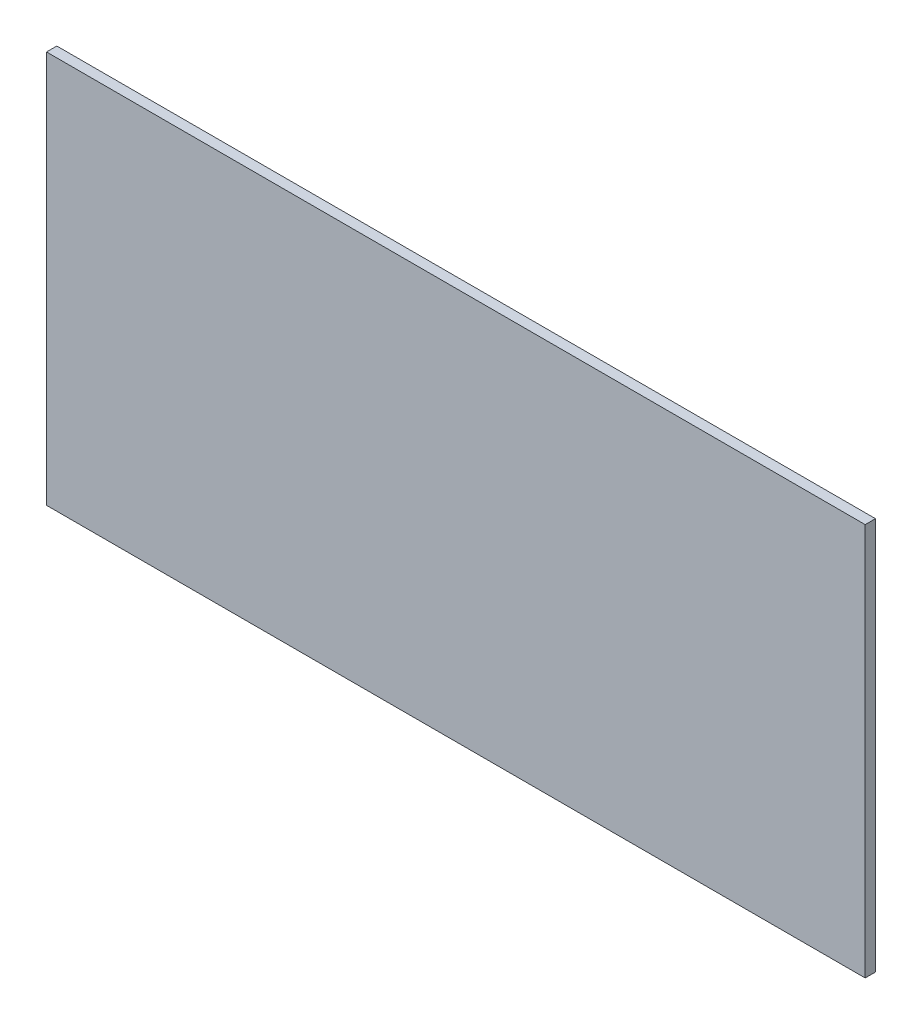
from build123d import *

# Parameters (mm, degrees)
SKETCH1_W           = 946.658829024
SKETCH1_H           = 454.025
BOSS_EXTRUDE1_DEPTH = 11.90625


with BuildPart() as part:
    # Sketch1 → Boss-Extrude1 (new body)
    with BuildSketch(Plane.XY):
        with Locations((0, 227.0125)):
            Rectangle(SKETCH1_W, SKETCH1_H)
    extrude(amount=-BOSS_EXTRUDE1_DEPTH)


solid = part.part
